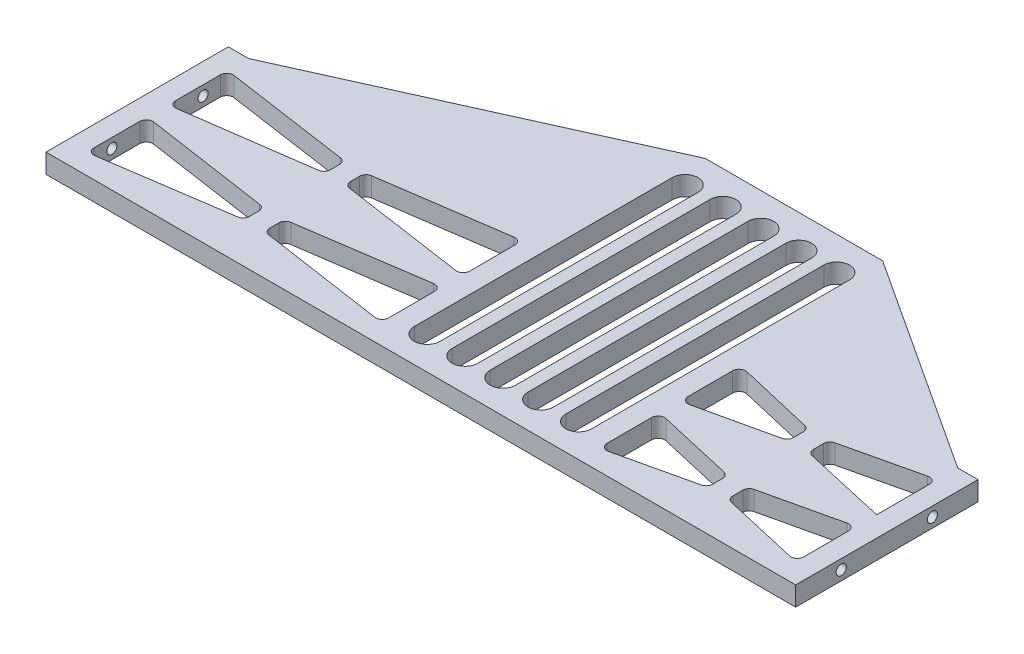
from build123d import *

# Parameters (mm, degrees)
BOSS_EXTRUDE1_DEPTH             = 4.763
TAP_DRILL_FOR_M3X0_5_TAP1_D     = 2.5
TAP_DRILL_FOR_M3X0_5_TAP1_DEPTH = 5
TAP_DRILL_FOR_M3X0_5_TAP2_D     = 2.5
TAP_DRILL_FOR_M3X0_5_TAP2_DEPTH = 5


with BuildPart() as part:
    # Sketch2 → Boss-Extrude1 (new body)
    with BuildSketch(Plane(origin=(0, 0, 0), x_dir=(1, 0, 0), z_dir=(0, 1, 0))):
        Polygon((-66.5, -22.5), (118.5, -22.5), (118.5, 22.5), (113.5, 22.5), (59.963, 57.5), (16.213, 57.5), (-61.5, 22.5), (-66.5, 22.5), align=None)
        with BuildLine():
            Line((50.613, 49.325), (50.613, -14.325))
            ThreePointArc((50.613, -14.325), (47.438, -17.5), (44.263, -14.325))
            Line((44.263, -14.325), (44.263, 49.325))
            ThreePointArc((44.263, 49.325), (47.438, 52.5), (50.613, 49.325))
        make_face(mode=Mode.SUBTRACT)
        with BuildLine():
            Line((41.263, 49.325), (41.263, -14.325))
            ThreePointArc((41.263, -14.325), (38.088, -17.5), (34.913, -14.325))
            Line((34.913, -14.325), (34.913, 49.325))
            ThreePointArc((34.913, 49.325), (38.088, 52.5), (41.263, 49.325))
        make_face(mode=Mode.SUBTRACT)
        with BuildLine():
            Line((31.913, 49.325), (31.913, -14.325))
            ThreePointArc((31.913, -14.325), (28.738, -17.5), (25.563, -14.325))
            Line((25.563, -14.325), (25.563, 49.325))
            ThreePointArc((25.563, 49.325), (28.738, 52.5), (31.913, 49.325))
        make_face(mode=Mode.SUBTRACT)
        with BuildLine():
            Line((59.963, 49.325), (59.963, -14.325))
            ThreePointArc((59.963, -14.325), (56.788, -17.5), (53.613, -14.325))
            Line((53.613, -14.325), (53.613, 49.325))
            ThreePointArc((53.613, 49.325), (56.788, 52.5), (59.963, 49.325))
        make_face(mode=Mode.SUBTRACT)
        with BuildLine():
            Line((22.563, 49.325), (22.563, -14.325))
            ThreePointArc((22.563, -14.325), (19.388, -17.5), (16.213, -14.325))
            Line((16.213, -14.325), (16.213, 49.325))
            ThreePointArc((16.213, 49.325), (19.388, 52.5), (22.563, 49.325))
        make_face(mode=Mode.SUBTRACT)
        with BuildLine():
            Line((-59.6842053, 17.076061462), (-29.0027053, 12.617481945))
            ThreePointArc((-29.0027053, 12.617481945), (-28.030463852, 12.085169259), (-27.6435, 11.04648297))
            Line((-27.6435, 11.04648297), (-27.6435, 8.800559076))
            ThreePointArc((-27.6435, 8.800559076), (-28.033123359, 7.758806801), (-29.010741325, 7.228413292))
            Line((-29.010741325, 7.228413292), (-59.692241325, 2.929914643))
            ThreePointArc((-59.692241325, 2.929914643), (-60.954252275, 3.304183785), (-61.5, 4.502060427))
            Line((-61.5, 4.502060427), (-61.5, 15.505062487))
            ThreePointArc((-61.5, 15.505062487), (-60.951186289, 16.705598635), (-59.6842053, 17.076061462))
        make_face(mode=Mode.SUBTRACT)
        with BuildLine():
            Line((-59.680570174, -2.76869727), (-28.999070174, -7.299806511))
            ThreePointArc((-28.999070174, -7.299806511), (-28.029262747, -7.832976538), (-27.6435, -8.87027294))
            Line((-27.6435, -8.87027294), (-27.6435, -11.12972706))
            ThreePointArc((-27.6435, -11.12972706), (-28.029262747, -12.167023462), (-28.999070174, -12.700193489))
            Line((-28.999070174, -12.700193489), (-59.680570174, -17.23130273))
            ThreePointArc((-59.680570174, -17.23130273), (-60.949796402, -16.862573553), (-61.5, -15.6608363))
            Line((-61.5, -15.6608363), (-61.5, -4.3391637))
            ThreePointArc((-61.5, -4.3391637), (-60.949796402, -3.137426447), (-59.680570174, -2.76869727))
        make_face(mode=Mode.SUBTRACT)
        with BuildLine():
            Line((-22.6435, -8.87027294), (-22.6435, -11.12972706))
            ThreePointArc((-22.6435, -11.12972706), (-22.257737253, -12.167023462), (-21.287929826, -12.700193489))
            Line((-21.287929826, -12.700193489), (9.393570174, -17.23130273))
            ThreePointArc((9.393570174, -17.23130273), (10.662796402, -16.862573553), (11.213, -15.6608363))
            Line((11.213, -15.6608363), (11.213, -4.3391637))
            ThreePointArc((11.213, -4.3391637), (10.662796402, -3.137426447), (9.393570174, -2.76869727))
            Line((9.393570174, -2.76869727), (-21.287929826, -7.299806511))
            ThreePointArc((-21.287929826, -7.299806511), (-22.257737253, -7.832976538), (-22.6435, -8.87027294))
        make_face(mode=Mode.SUBTRACT)
        with BuildLine():
            Line((-22.6435, 8.79344646), (-22.6435, 11.04648297))
            ThreePointArc((-22.6435, 11.04648297), (-22.256536148, 12.085169259), (-21.2842947, 12.617481945))
            Line((-21.2842947, 12.617481945), (9.3972053, 17.076061462))
            ThreePointArc((9.3972053, 17.076061462), (10.664186289, 16.705598635), (11.213, 15.505062487))
            Line((11.213, 15.505062487), (11.213, 4.334866943))
            ThreePointArc((11.213, 4.334866943), (10.664186289, 3.134330795), (9.3972053, 2.763867968))
            Line((9.3972053, 2.763867968), (-21.2842947, 7.222447484))
            ThreePointArc((-21.2842947, 7.222447484), (-22.256536148, 7.754760171), (-22.6435, 8.79344646))
        make_face(mode=Mode.SUBTRACT)
        with BuildLine():
            Line((64.963, 15.499376461), (64.963, 4.486336964))
            ThreePointArc((64.963, 4.486336964), (65.559394235, 3.246229867), (66.900468488, 2.93789313))
            Line((66.900468488, 2.93789313), (85.493968488, 7.140266464))
            ThreePointArc((85.493968488, 7.140266464), (86.384107097, 7.697604533), (86.7315, 8.688710298))
            Line((86.7315, 8.688710298), (86.7315, 11.160279322))
            ThreePointArc((86.7315, 11.160279322), (86.387560859, 12.147048109), (85.504775415, 12.706240948))
            Line((85.504775415, 12.706240948), (66.911275415, 17.045338087))
            ThreePointArc((66.911275415, 17.045338087), (65.563731213, 16.74293732), (64.963, 15.499376461))
        make_face(mode=Mode.SUBTRACT)
        with BuildLine():
            Line((91.7315, 11.160279322), (91.7315, 8.688710298))
            ThreePointArc((91.7315, 8.688710298), (92.078892903, 7.697604533), (92.969031512, 7.140266464))
            Line((92.969031512, 7.140266464), (113.5, 2.5))
            Line((113.5, 2.5), (113.5, 15.499376461))
            ThreePointArc((113.5, 15.499376461), (112.899268787, 16.74293732), (111.551724585, 17.045338087))
            Line((111.551724585, 17.045338087), (92.958224585, 12.706240948))
            ThreePointArc((92.958224585, 12.706240948), (92.075439141, 12.147048109), (91.7315, 11.160279322))
        make_face(mode=Mode.SUBTRACT)
        with BuildLine():
            Line((86.7315, -8.764205555), (86.7315, -11.235794445))
            ThreePointArc((86.7315, -11.235794445), (86.385837257, -12.22473149), (85.499378453, -12.783005615))
            Line((85.499378453, -12.783005615), (66.905878453, -17.053740852))
            ThreePointArc((66.905878453, -17.053740852), (65.561562955, -16.748366938), (64.963, -15.506529682))
            Line((64.963, -15.506529682), (64.963, -4.493470318))
            ThreePointArc((64.963, -4.493470318), (65.561562955, -3.251633062), (66.905878453, -2.946259148))
            Line((66.905878453, -2.946259148), (85.499378453, -7.216994385))
            ThreePointArc((85.499378453, -7.216994385), (86.385837257, -7.77526851), (86.7315, -8.764205555))
        make_face(mode=Mode.SUBTRACT)
        with BuildLine():
            Line((91.7315, -8.764205555), (91.7315, -11.235794445))
            ThreePointArc((91.7315, -11.235794445), (92.077162743, -12.22473149), (92.963621547, -12.783005615))
            Line((92.963621547, -12.783005615), (111.557121547, -17.053740852))
            ThreePointArc((111.557121547, -17.053740852), (112.901437045, -16.748366938), (113.5, -15.506529682))
            Line((113.5, -15.506529682), (113.5, -4.493470318))
            ThreePointArc((113.5, -4.493470318), (112.901437045, -3.251633062), (111.557121547, -2.946259148))
            Line((111.557121547, -2.946259148), (92.963621547, -7.216994385))
            ThreePointArc((92.963621547, -7.216994385), (92.077162743, -7.77526851), (91.7315, -8.764205555))
        make_face(mode=Mode.SUBTRACT)
    extrude(amount=BOSS_EXTRUDE1_DEPTH)

    # Tap Drill for M3x0.5 Tap1
    with Locations(Plane(origin=(118.5, 0, 0), x_dir=(0, 0, -1), z_dir=(1, 0, 0))):
        with Locations((-11.25, 2.3815), (11.25, 2.3815)):
            Hole(TAP_DRILL_FOR_M3X0_5_TAP1_D / 2, depth=TAP_DRILL_FOR_M3X0_5_TAP1_DEPTH)

    # Tap Drill for M3x0.5 Tap2
    with Locations(Plane.ZY.offset(66.5)):
        with Locations((11.25, 2.3815), (-11.25, 2.3815)):
            Hole(TAP_DRILL_FOR_M3X0_5_TAP2_D / 2, depth=TAP_DRILL_FOR_M3X0_5_TAP2_DEPTH)


solid = part.part
